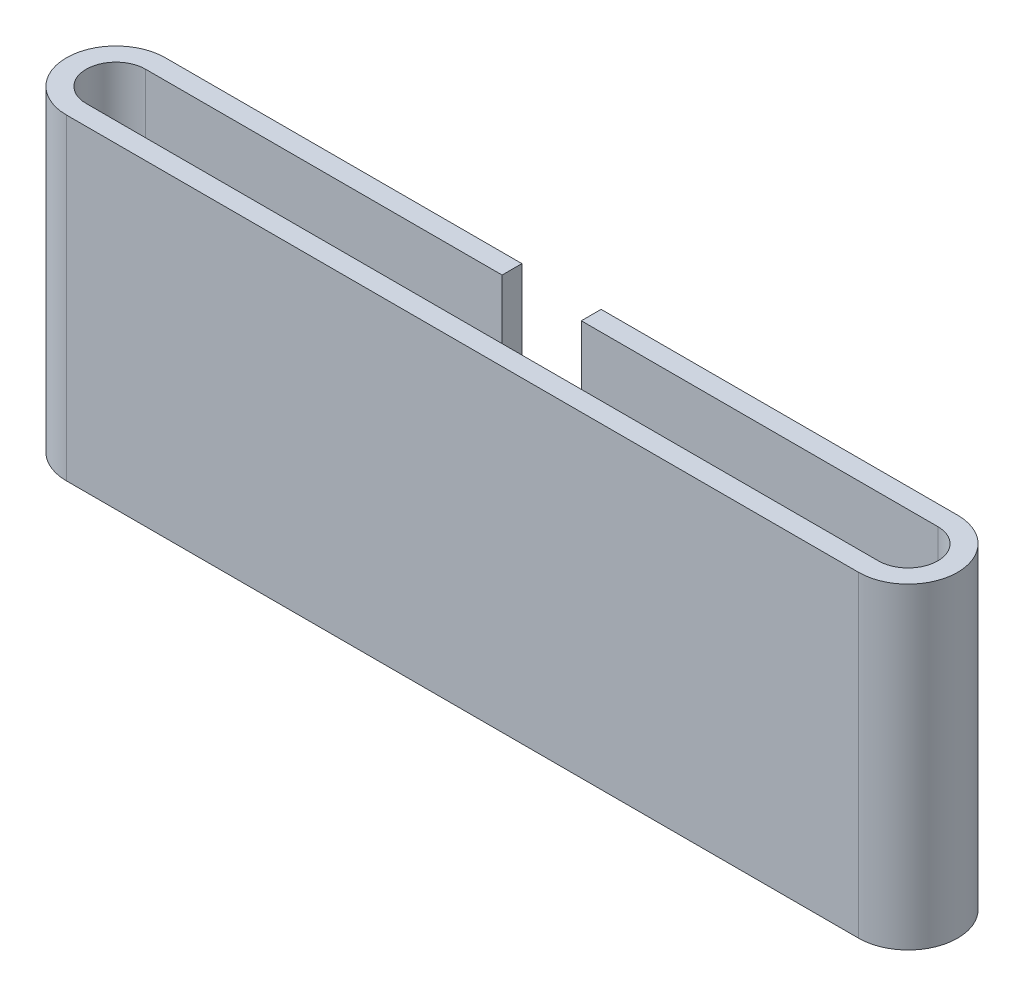
from build123d import *

# Parameters (mm, degrees)
EXTRUDE_1_DEPTH     = 30
EXTRUDE_2_DEPTH     = 2
SKETCH_3_W          = 8
SKETCH_3_H          = 2.352392564
CUT_EXTRUDE_1_DEPTH = 30


with BuildPart() as part:
    # 草圖1 → 填料-伸長1 (new body)
    with BuildSketch(Plane(origin=(0, 0, 0), x_dir=(1, 0, 0), z_dir=(0, 1, 0))):
        with BuildLine():
            Line((-20, 5), (60, 5))
            ThreePointArc((60, 5), (65, 0), (60, -5))
            Line((60, -5), (-20, -5))
            ThreePointArc((-20, -5), (-25, 0), (-20, 5))
        make_face()
        with BuildLine():
            Line((-20, 3), (60, 3))
            ThreePointArc((60, 3), (63, 0), (60, -3))
            Line((60, -3), (-20, -3))
            ThreePointArc((-20, -3), (-23, 0), (-20, 3))
        make_face(mode=Mode.SUBTRACT)
    extrude(amount=EXTRUDE_1_DEPTH)

    # 草圖2 → 填料-伸長2 (add)
    with BuildSketch(Plane.XZ):
        with BuildLine():
            Line((-20, -5), (60, -5))
            ThreePointArc((60, -5), (65, 0), (60, 5))
            Line((60, 5), (-20, 5))
            ThreePointArc((-20, 5), (-25, 0), (-20, -5))
        make_face()
    extrude(amount=EXTRUDE_2_DEPTH)

    # 草圖3 → 除料-伸長1 (cut)
    with BuildSketch(Plane(origin=(0, 30, 0), x_dir=(1, 0, 0), z_dir=(0, 1, 0))):
        with Locations((20, 3.823803718)):
            Rectangle(SKETCH_3_W, SKETCH_3_H)
    extrude(amount=-CUT_EXTRUDE_1_DEPTH, mode=Mode.SUBTRACT)


solid = part.part
